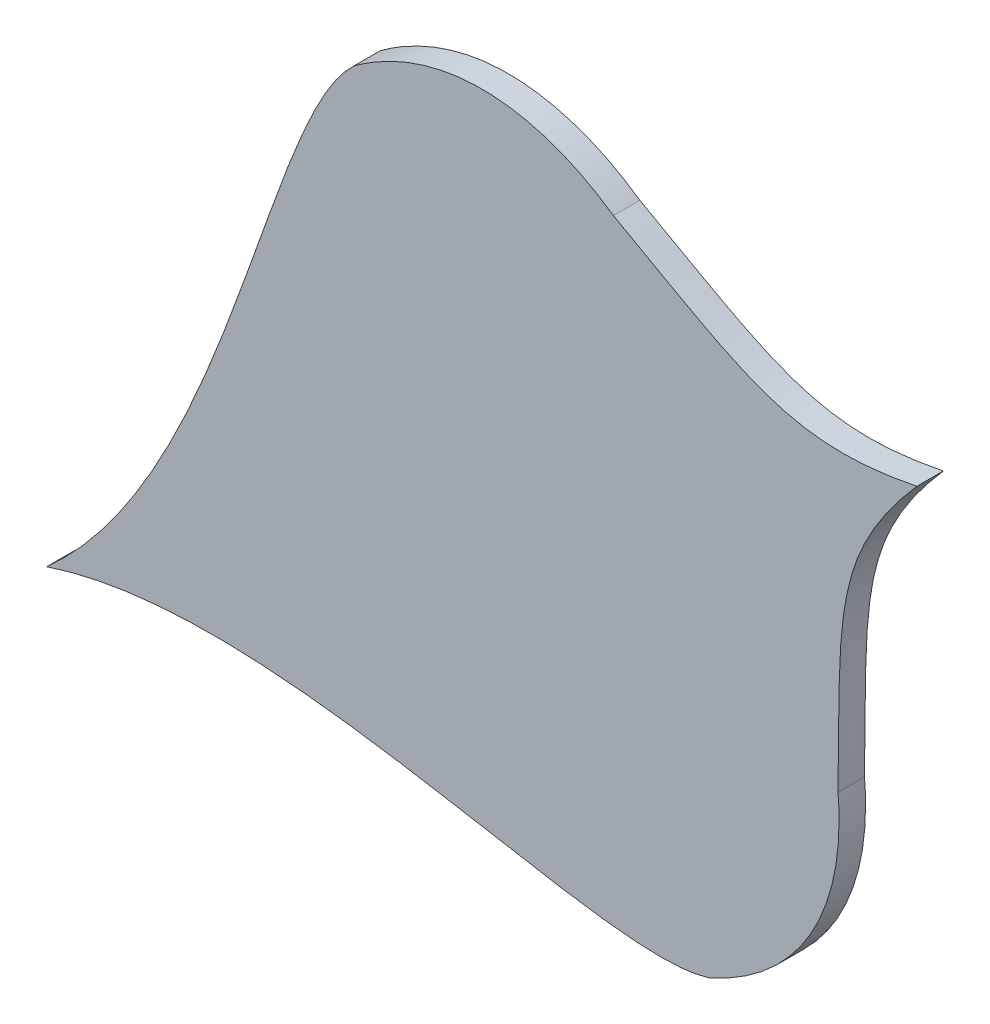
from build123d import *

# Parameters (mm, degrees)
BOSS_EXTRUDE1_DEPTH = 10


with BuildPart() as part:
    # Sketch1 → Boss-Extrude1 (new body)
    with BuildSketch(Plane.XY):
        with BuildLine():
            add(Edge.make_bspline(
                [(1415.7693798, 1031.046835581), (1367.628210311, 1021.339100434), (1351.545709895, 1034.491042003), (1301.21719942, 1062.281192228)],
                knots=[0, 0, 0, 0, 1, 1, 1, 1], degree=3))
            add(Edge.make_bspline(
                [(1301.21719942, 1062.281192228), (1274.485473897, 1081.017650054), (1237.922941256, 1087.540678103), (1203.284773936, 1062.288290276)],
                knots=[0, 0, 0, 0, 1, 1, 1, 1], degree=3))
            add(Edge.make_bspline(
                [(1203.284773936, 1062.288290276), (1170.198368602, 1031.598934224), (1156.257012178, 901.986996511), (1087.249339763, 840.498155001)],
                knots=[0, 0, 0, 0, 1, 1, 1, 1], degree=3))
            add(Edge.make_bspline(
                [(1337.382589735, 831.093722667), (1294.315235342, 817.612262121), (1174.887236961, 869.867108969), (1087.249339763, 840.498155001)],
                knots=[0, 0, 0, 0, 1, 1, 1, 1], degree=3))
            add(Edge.make_bspline(
                [(1386.002816787, 916.10450747), (1388.993324609, 883.597633363), (1376.501045784, 848.621760854), (1337.382589735, 831.093722667)],
                knots=[0, 0, 0, 0, 1, 1, 1, 1], degree=3))
            add(Edge.make_bspline(
                [(1415.7693798, 1031.046835581), (1383.439340443, 994.079540892), (1386.870038806, 973.589282342), (1386.002816787, 916.10450747)],
                knots=[0, 0, 0, 0, 1, 1, 1, 1], degree=3))
        make_face()
    extrude(amount=BOSS_EXTRUDE1_DEPTH)


solid = part.part
